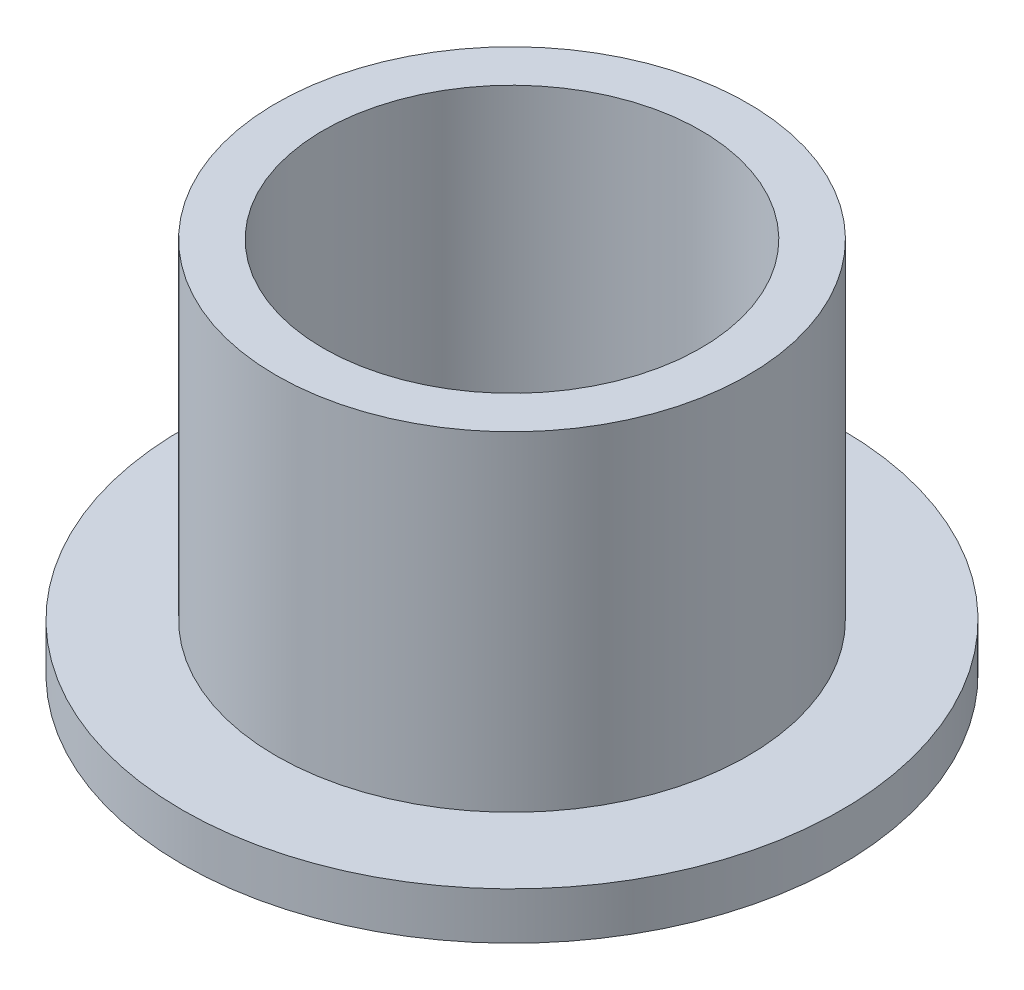
from build123d import *

# Parameters (mm, degrees)
SKETCH2_R           = 7.9502
SKETCH2_R_2         = 6.3627
BOSS_EXTRUDE1_DEPTH = 12.7
SKETCH3_R           = 11.1125
SKETCH3_R_2         = 7.9502
BOSS_EXTRUDE2_DEPTH = 1.5875


with BuildPart() as part:
    # Sketch2 → Boss-Extrude1 (new body)
    with BuildSketch(Plane(origin=(0, 0, 0), x_dir=(1, 0, 0), z_dir=(0, 1, 0))):
        Circle(SKETCH2_R)
        Circle(SKETCH2_R_2, mode=Mode.SUBTRACT)
    extrude(amount=BOSS_EXTRUDE1_DEPTH)

    # Sketch3 → Boss-Extrude2 (add)
    with BuildSketch(Plane(origin=(0, 0, 0), x_dir=(1, 0, 0), z_dir=(0, 1, 0))):
        Circle(SKETCH3_R)
        Circle(SKETCH3_R_2, mode=Mode.SUBTRACT)
    extrude(amount=BOSS_EXTRUDE2_DEPTH)


solid = part.part
